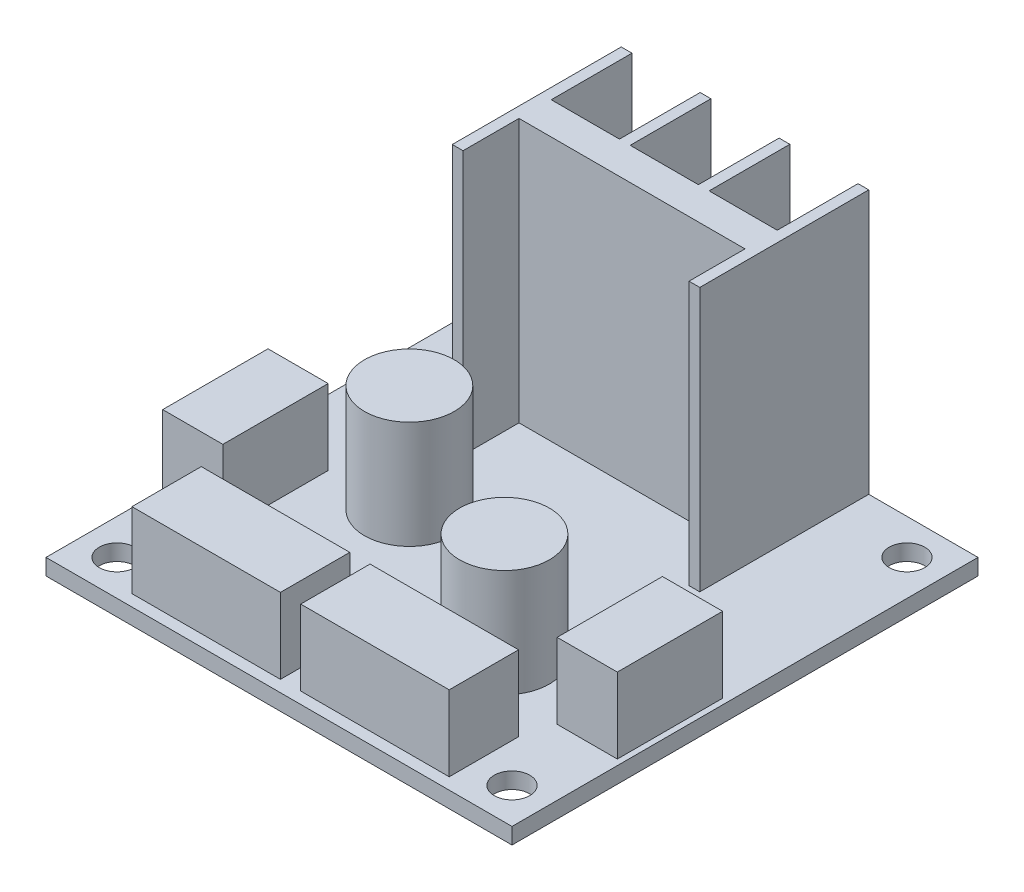
from build123d import *

# Parameters (mm, degrees)
SKETCH1_W           = 43.3
SKETCH1_H           = 43.3
SKETCH1_R           = 1.65
BOSS_EXTRUDE1_DEPTH = 1.5
SKETCH2_W           = 23
SKETCH2_H           = 15.7
BOSS_EXTRUDE2_DEPTH = 24.5
SKETCH3_W           = 5.591942039
SKETCH3_H           = 9.785898568
SKETCH3_W_2         = 13.797509161
SKETCH3_H_2         = 6.44288974
BOSS_EXTRUDE3_DEPTH = 7
SKETCH4_R           = 4.168434161
BOSS_EXTRUDE4_DEPTH = 10
SKETCH5_W           = 21
SKETCH5_H           = 5.2
SKETCH5_W_2         = 6.333333334
SKETCH5_H_2         = 15
SKETCH5_W_3         = 6.333333333
CUT_EXTRUDE1_DEPTH  = 24.5


with BuildPart() as part:
    # Sketch1 → Boss-Extrude1 (new body)
    with BuildSketch(Plane(origin=(0, 0, 0), x_dir=(1, 0, 0), z_dir=(0, 1, 0))):
        Rectangle(SKETCH1_W, SKETCH1_H)
        with Locations((-18.35, 18.35)):
            Circle(SKETCH1_R, mode=Mode.SUBTRACT)
        with Locations((18.35, 18.35)):
            Circle(SKETCH1_R, mode=Mode.SUBTRACT)
        with Locations((-18.35, -18.35)):
            Circle(SKETCH1_R, mode=Mode.SUBTRACT)
        with Locations((18.35, -18.35)):
            Circle(SKETCH1_R, mode=Mode.SUBTRACT)
    extrude(amount=BOSS_EXTRUDE1_DEPTH)

    # Sketch2 → Boss-Extrude2 (add)
    with BuildSketch(Plane(origin=(0, 1.5, 0), x_dir=(1, 0, 0), z_dir=(0, 1, 0))):
        with Locations((0, 13.8)):
            Rectangle(SKETCH2_W, SKETCH2_H)
    extrude(amount=BOSS_EXTRUDE2_DEPTH)

    # Sketch3 → Boss-Extrude3 (add)
    with BuildSketch(Plane(origin=(0, 1.5, 0), x_dir=(1, 0, 0), z_dir=(0, 1, 0))):
        with Locations((-18.325766573, -6.44288974)):
            Rectangle(SKETCH3_W, SKETCH3_H)
        with Locations((-7.84087525, -17.353254914)):
            Rectangle(SKETCH3_W_2, SKETCH3_H_2)
    boss_extrude3 = extrude(amount=BOSS_EXTRUDE3_DEPTH)

    # Mirror1: Boss-Extrude3 across plane
    add(boss_extrude3.mirror(Plane(origin=(0, 0, 0), x_dir=(0, 0, 1), z_dir=(1, 0, 0))))

    # Sketch4 → Boss-Extrude4 (add)
    with BuildSketch(Plane(origin=(0, 1.5, 0), x_dir=(1, 0, 0), z_dir=(0, 1, 0))):
        with Locations((-8.592825404, -0.943272563)):
            Circle(SKETCH4_R)
        with Locations((7.765846719, -8.463609984)):
            Circle(SKETCH4_R)
    extrude(amount=BOSS_EXTRUDE4_DEPTH)

    # Sketch5 → Cut-Extrude1 (cut)
    with BuildSketch(Plane(origin=(0, 26, 0), x_dir=(1, 0, 0), z_dir=(0, 1, 0))):
        with Locations((0, 8.55)):
            Rectangle(SKETCH5_W, SKETCH5_H)
        with Locations((0, 21.65)):
            Rectangle(SKETCH5_W_2, SKETCH5_H_2)
        with Locations((7.333333334, 21.65)):
            Rectangle(SKETCH5_W_3, SKETCH5_H_2)
        with Locations((-7.333333334, 21.65)):
            Rectangle(SKETCH5_W_3, SKETCH5_H_2)
    extrude(amount=-CUT_EXTRUDE1_DEPTH, mode=Mode.SUBTRACT)


solid = part.part
